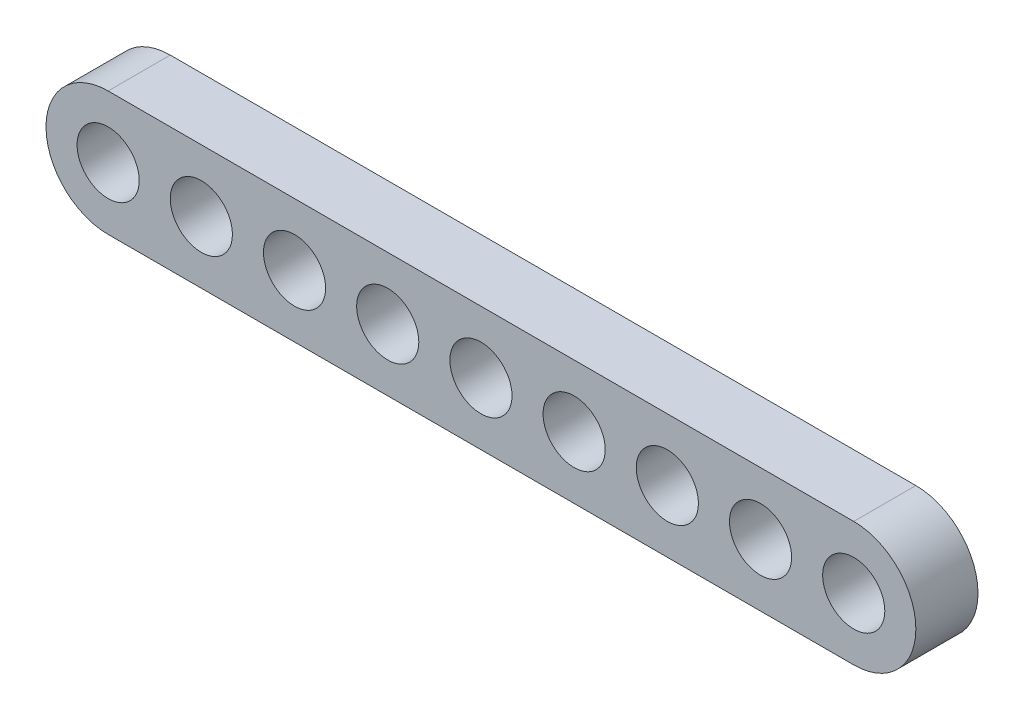
from build123d import *

# Parameters (mm, degrees)
SKETCH1_R           = 5
BOSS_EXTRUDE1_DEPTH = 10


with BuildPart() as part:
    # Sketch1 → Boss-Extrude1 (new body)
    with BuildSketch(Plane.XY):
        with BuildLine():
            Line((-60, 10), (60, 10))
            ThreePointArc((60, 10), (70, 0), (60, -10))
            Line((60, -10), (-60, -10))
            ThreePointArc((-60, -10), (-70, 0), (-60, 10))
        make_face()
        with Locations((-60, 0)):
            Circle(SKETCH1_R, mode=Mode.SUBTRACT)
        with Locations((-45, 0)):
            Circle(SKETCH1_R, mode=Mode.SUBTRACT)
        with Locations((-30, 0)):
            Circle(SKETCH1_R, mode=Mode.SUBTRACT)
        with Locations((-15, 0)):
            Circle(SKETCH1_R, mode=Mode.SUBTRACT)
        Circle(SKETCH1_R, mode=Mode.SUBTRACT)
        with Locations((15, 0)):
            Circle(SKETCH1_R, mode=Mode.SUBTRACT)
        with Locations((30, 0)):
            Circle(SKETCH1_R, mode=Mode.SUBTRACT)
        with Locations((45, 0)):
            Circle(SKETCH1_R, mode=Mode.SUBTRACT)
        with Locations((60, 0)):
            Circle(SKETCH1_R, mode=Mode.SUBTRACT)
    extrude(amount=BOSS_EXTRUDE1_DEPTH)


solid = part.part
